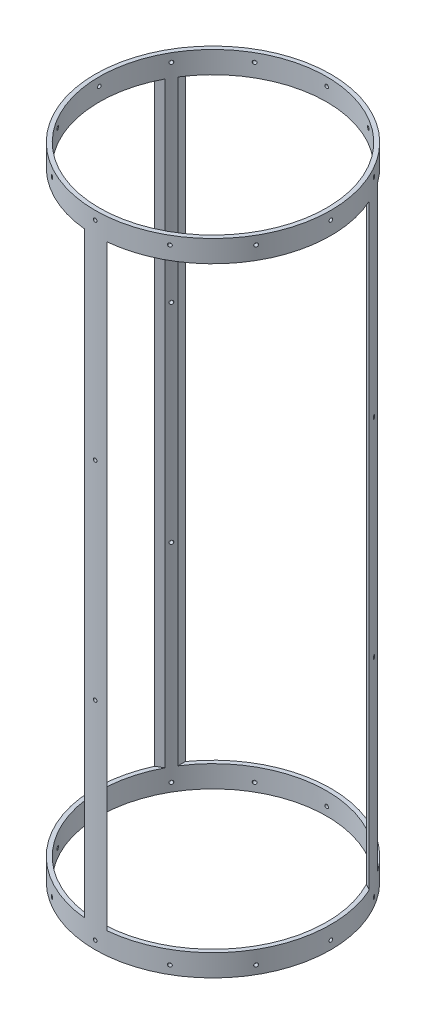
from build123d import *

# Parameters (mm, degrees)
SKETCH1_R                = 88.9
SKETCH1_R_2              = 85.725
BOSS_EXTRUDE1_DEPTH      = 241.427
CUT_EXTRUDE1_START       = -88.9
SKETCH2_W                = 144.78
SKETCH2_H                = 449.834
CUT_EXTRUDE1_DEPTH       = 42.981991
CIRPATTERN1_COUNT        = 3
SKETCH4_R                = 1.35255
CUT_EXTRUDE3_DEPTH       = 15.24
CIRPATTERN3_COUNT        = 12
MIRROR1_COPY_1_SKETCH_R  = 1.35255
MIRROR1_COPY_1_DEPTH     = 15.24
MIRROR1_COPY_2_SKETCH_R  = 1.35255
MIRROR1_COPY_2_DEPTH     = 15.24
MIRROR1_COPY_3_SKETCH_R  = 1.35255
MIRROR1_COPY_3_DEPTH     = 15.24
MIRROR1_COPY_4_SKETCH_R  = 1.35255
MIRROR1_COPY_4_DEPTH     = 15.24
MIRROR1_COPY_5_SKETCH_R  = 1.35255
MIRROR1_COPY_5_DEPTH     = 15.24
MIRROR1_COPY_6_SKETCH_R  = 1.35255
MIRROR1_COPY_6_DEPTH     = 15.24
MIRROR1_COPY_7_SKETCH_R  = 1.35255
MIRROR1_COPY_7_DEPTH     = 15.24
MIRROR1_COPY_8_SKETCH_R  = 1.35255
MIRROR1_COPY_8_DEPTH     = 15.24
MIRROR1_COPY_9_SKETCH_R  = 1.35255
MIRROR1_COPY_9_DEPTH     = 15.24
MIRROR1_COPY_10_SKETCH_R = 1.35255
MIRROR1_COPY_10_DEPTH    = 15.24
MIRROR1_COPY_11_SKETCH_R = 1.35255
MIRROR1_COPY_11_DEPTH    = 15.24
SKETCH5_R                = 1.35255
CUT_EXTRUDE4_DEPTH       = 22.86
CIRPATTERN4_COUNT        = 3


with BuildPart() as part:
    # Sketch1 → Boss-Extrude1 (new body, symmetric)
    with BuildSketch(Plane(origin=(0, 0, 0), x_dir=(1, 0, 0), z_dir=(0, 1, 0))):
        Circle(SKETCH1_R)
        Circle(SKETCH1_R_2, mode=Mode.SUBTRACT)
    extrude(amount=BOSS_EXTRUDE1_DEPTH, both=True)

    # Sketch2 → Cut-Extrude1 (cut)
    with BuildSketch(Plane.XY.offset(CUT_EXTRUDE1_START)):
        Rectangle(SKETCH2_W, SKETCH2_H)
    cut_extrude1 = extrude(amount=CUT_EXTRUDE1_DEPTH, mode=Mode.SUBTRACT)

    # CirPattern1: Cut-Extrude1 ×3 about axis
    cirpattern1_axis = Axis((0, 0, 0), (0, 1, 0))
    for i in range(1, CIRPATTERN1_COUNT):
        add(cut_extrude1.rotate(cirpattern1_axis, i * 360 / CIRPATTERN1_COUNT), mode=Mode.SUBTRACT)

    # Sketch4 → Cut-Extrude3 (cut)
    with BuildSketch(Plane(origin=(88.9, 0, 0), x_dir=(0, 0, -1), z_dir=(1, 0, 0))):
        with Locations((0, 235.077)):
            Circle(SKETCH4_R)
    cut_extrude3 = extrude(amount=-CUT_EXTRUDE3_DEPTH, mode=Mode.SUBTRACT)

    # CirPattern3: Cut-Extrude3 ×12 about axis
    cirpattern3_axis = Axis((0, 241.427, 0), (0, -1, 0))
    for i in range(1, CIRPATTERN3_COUNT):
        add(cut_extrude3.rotate(cirpattern3_axis, i * 360 / CIRPATTERN3_COUNT), mode=Mode.SUBTRACT)

    # Mirror1: Cut-Extrude3 across plane
    add(cut_extrude3.mirror(Plane.ZX), mode=Mode.SUBTRACT)

    # Mirror1 copy 1 sketch → Mirror1 copy 1 (cut)
    with BuildSketch(Plane(origin=(76.989658396, 0, 44.45), x_dir=(0.5, 0, -0.866025404), z_dir=(0.866025404, 0, 0.5))):
        with Locations((0, -235.077)):
            Circle(MIRROR1_COPY_1_SKETCH_R)
    extrude(amount=-MIRROR1_COPY_1_DEPTH, mode=Mode.SUBTRACT)

    # Mirror1 copy 2 sketch → Mirror1 copy 2 (cut)
    with BuildSketch(Plane(origin=(44.45, 0, 76.989658396), x_dir=(0.866025404, 0, -0.5), z_dir=(0.5, 0, 0.866025404))):
        with Locations((0, -235.077)):
            Circle(MIRROR1_COPY_2_SKETCH_R)
    extrude(amount=-MIRROR1_COPY_2_DEPTH, mode=Mode.SUBTRACT)

    # Mirror1 copy 3 sketch → Mirror1 copy 3 (cut)
    with BuildSketch(Plane.XY.offset(88.9)):
        with Locations((0, -235.077)):
            Circle(MIRROR1_COPY_3_SKETCH_R)
    extrude(amount=-MIRROR1_COPY_3_DEPTH, mode=Mode.SUBTRACT)

    # Mirror1 copy 4 sketch → Mirror1 copy 4 (cut)
    with BuildSketch(Plane(origin=(-44.45, 0, 76.989658396), x_dir=(0.866025404, 0, 0.5), z_dir=(-0.5, 0, 0.866025404))):
        with Locations((0, -235.077)):
            Circle(MIRROR1_COPY_4_SKETCH_R)
    extrude(amount=-MIRROR1_COPY_4_DEPTH, mode=Mode.SUBTRACT)

    # Mirror1 copy 5 sketch → Mirror1 copy 5 (cut)
    with BuildSketch(Plane(origin=(-76.989658396, 0, 44.45), x_dir=(0.5, 0, 0.866025404), z_dir=(-0.866025404, 0, 0.5))):
        with Locations((0, -235.077)):
            Circle(MIRROR1_COPY_5_SKETCH_R)
    extrude(amount=-MIRROR1_COPY_5_DEPTH, mode=Mode.SUBTRACT)

    # Mirror1 copy 6 sketch → Mirror1 copy 6 (cut)
    with BuildSketch(Plane.ZY.offset(88.9)):
        with Locations((0, -235.077)):
            Circle(MIRROR1_COPY_6_SKETCH_R)
    extrude(amount=-MIRROR1_COPY_6_DEPTH, mode=Mode.SUBTRACT)

    # Mirror1 copy 7 sketch → Mirror1 copy 7 (cut)
    with BuildSketch(Plane(origin=(-76.989658396, 0, -44.45), x_dir=(-0.5, 0, 0.866025404), z_dir=(-0.866025404, 0, -0.5))):
        with Locations((0, -235.077)):
            Circle(MIRROR1_COPY_7_SKETCH_R)
    extrude(amount=-MIRROR1_COPY_7_DEPTH, mode=Mode.SUBTRACT)

    # Mirror1 copy 8 sketch → Mirror1 copy 8 (cut)
    with BuildSketch(Plane(origin=(-44.45, 0, -76.989658396), x_dir=(-0.866025404, 0, 0.5), z_dir=(-0.5, 0, -0.866025404))):
        with Locations((0, -235.077)):
            Circle(MIRROR1_COPY_8_SKETCH_R)
    extrude(amount=-MIRROR1_COPY_8_DEPTH, mode=Mode.SUBTRACT)

    # Mirror1 copy 9 sketch → Mirror1 copy 9 (cut)
    with BuildSketch(Plane(origin=(0, 0, -88.9), x_dir=(-1, 0, 0), z_dir=(0, 0, -1))):
        with Locations((0, -235.077)):
            Circle(MIRROR1_COPY_9_SKETCH_R)
    extrude(amount=-MIRROR1_COPY_9_DEPTH, mode=Mode.SUBTRACT)

    # Mirror1 copy 10 sketch → Mirror1 copy 10 (cut)
    with BuildSketch(Plane(origin=(44.45, 0, -76.989658396), x_dir=(-0.866025404, 0, -0.5), z_dir=(0.5, 0, -0.866025404))):
        with Locations((0, -235.077)):
            Circle(MIRROR1_COPY_10_SKETCH_R)
    extrude(amount=-MIRROR1_COPY_10_DEPTH, mode=Mode.SUBTRACT)

    # Mirror1 copy 11 sketch → Mirror1 copy 11 (cut)
    with BuildSketch(Plane(origin=(76.989658396, 0, -44.45), x_dir=(-0.5, 0, -0.866025404), z_dir=(0.866025404, 0, -0.5))):
        with Locations((0, -235.077)):
            Circle(MIRROR1_COPY_11_SKETCH_R)
    extrude(amount=-MIRROR1_COPY_11_DEPTH, mode=Mode.SUBTRACT)

    # Sketch5 → Cut-Extrude4 (cut)
    with BuildSketch(Plane.XY.offset(88.9)):
        with Locations((0, 78.359)):
            Circle(SKETCH5_R)
        with Locations((0, -78.359)):
            Circle(SKETCH5_R)
    cut_extrude4 = extrude(amount=-CUT_EXTRUDE4_DEPTH, mode=Mode.SUBTRACT)

    # CirPattern4: Cut-Extrude4 ×3 about axis
    cirpattern4_axis = Axis((0, 241.427, 0), (0, -1, 0))
    for i in range(1, CIRPATTERN4_COUNT):
        add(cut_extrude4.rotate(cirpattern4_axis, i * 360 / CIRPATTERN4_COUNT), mode=Mode.SUBTRACT)


solid = part.part
